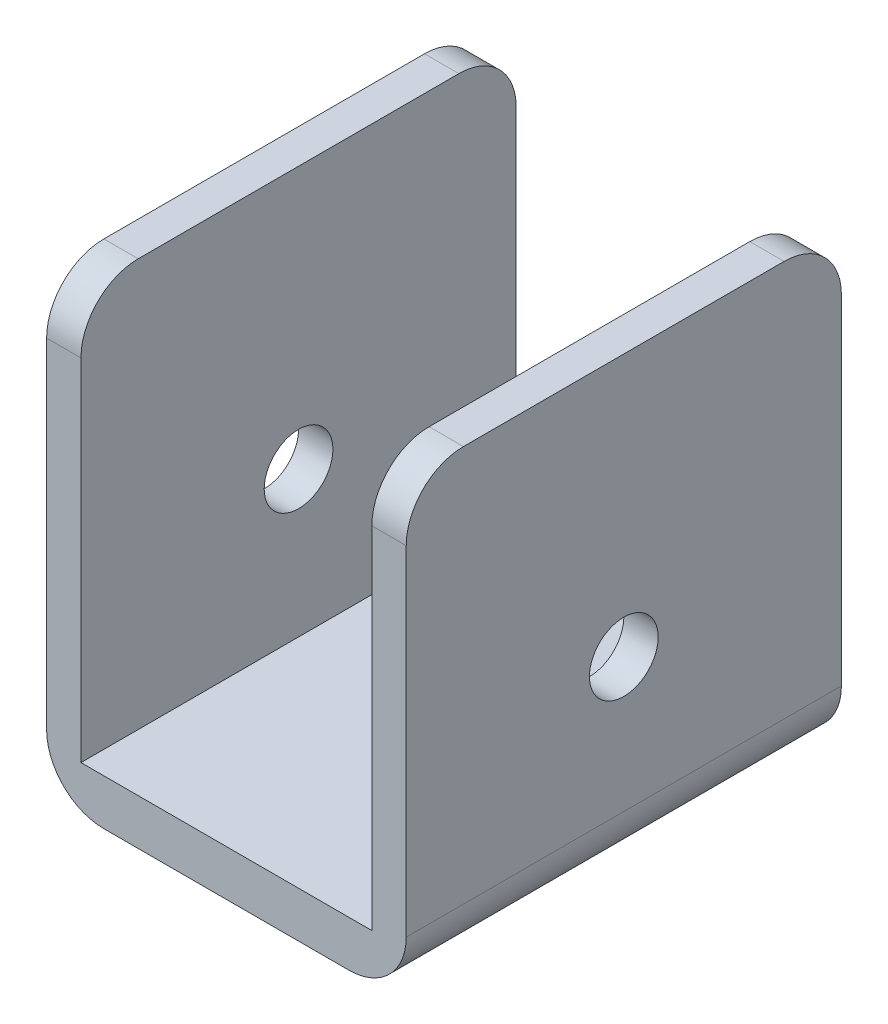
from build123d import *

# Parameters (mm, degrees)
BOSS_EXTRUDE1_DEPTH = 19
SKETCH2_R           = 3
CUT_EXTRUDE1_DEPTH  = 32.4
FILLET1_R           = 5


with BuildPart() as part:
    # Sketch1 → Boss-Extrude1 (new body, symmetric)
    with BuildSketch(Plane.XY):
        Polygon((-15.7, 39.6), (-12.7, 39.6), (-12.7, 4), (12.7, 4), (12.7, 39.6), (15.7, 39.6), (15.7, 0), (-15.7, 0), align=None)
    extrude(amount=BOSS_EXTRUDE1_DEPTH, both=True)

    # Sketch2 → Cut-Extrude1 (cut, through all)
    with BuildSketch(Plane(origin=(15.7, 0, 0), x_dir=(0, 0, -1), z_dir=(1, 0, 0))):
        with Locations((0, 16.7)):
            Circle(SKETCH2_R)
    extrude(amount=-CUT_EXTRUDE1_DEPTH, mode=Mode.SUBTRACT)

    # Fillet1
    fillet1_edges = [part.edges().sort_by_distance(p)[0] for p in [
        (14.2, 39.6, -19),
        (15.7, 0, 0),
        (-15.7, 0, 0),
        (14.2, 39.6, 19),
        (-14.2, 39.6, 19),
        (-14.2, 39.6, -19),
    ]]
    fillet(fillet1_edges, radius=FILLET1_R)


solid = part.part
